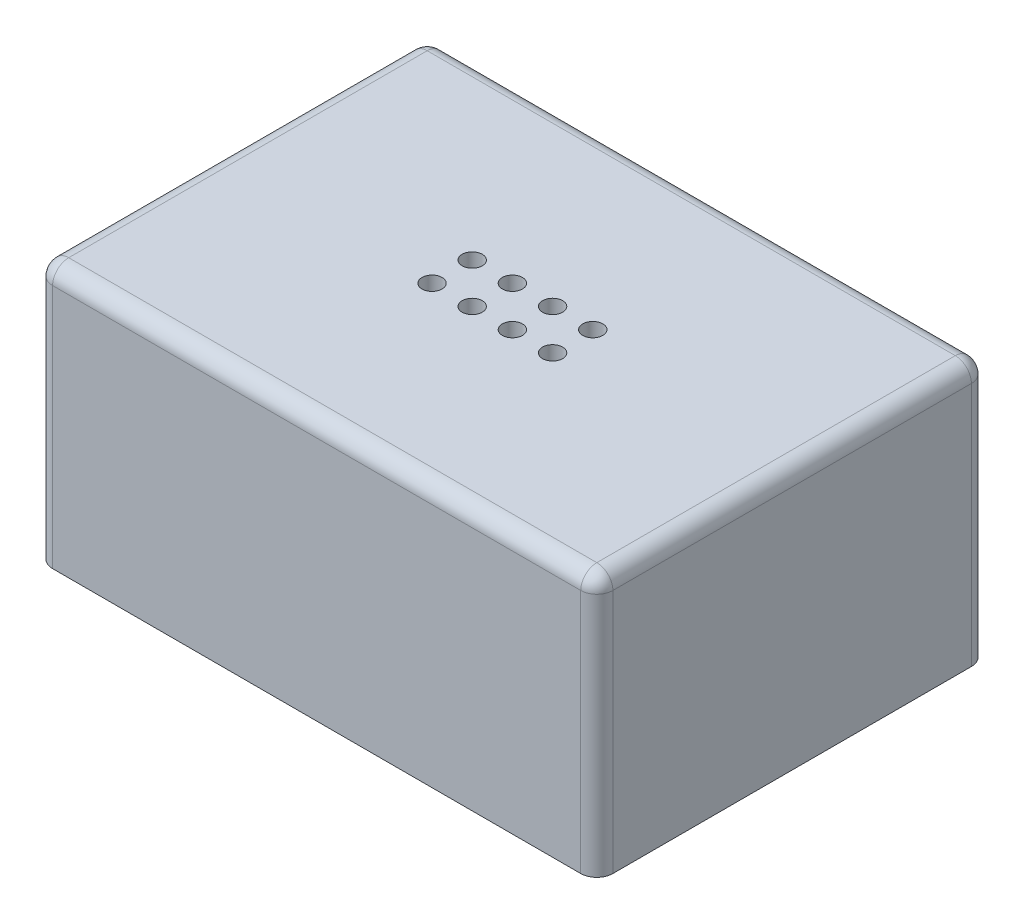
from build123d import *

# Parameters (mm, degrees)
SKETCH3_W           = 88.519
SKETCH3_H           = 61.722
BOSS_EXTRUDE2_DEPTH = 41.275
SKETCH1_W           = 85.344
SKETCH1_H           = 58.547
CUT_EXTRUDE1_DEPTH  = 38.1
FILLET2_R           = 2.54
SKETCH6_R           = 1.5875
CUT_EXTRUDE4_DEPTH  = 42.275
FILLET3_R           = 2.54


with BuildPart() as part:
    # Sketch3 → Boss-Extrude2 (new body)
    with BuildSketch(Plane(origin=(0, 0, 0), x_dir=(1, 0, 0), z_dir=(0, 1, 0))):
        Rectangle(SKETCH3_W, SKETCH3_H)
    extrude(amount=BOSS_EXTRUDE2_DEPTH)

    # Sketch1 → Cut-Extrude1 (cut)
    with BuildSketch(Plane(origin=(0, 0, 0), x_dir=(1, 0, 0), z_dir=(0, 1, 0))):
        Rectangle(SKETCH1_W, SKETCH1_H)
    extrude(amount=CUT_EXTRUDE1_DEPTH, mode=Mode.SUBTRACT)

    # Fillet2
    fillet2_edges = [part.edges().sort_by_distance(p)[0] for p in [
        (-44.2595, 41.275, 0),
        (0, 41.275, 30.861),
        (44.2595, 41.275, 0),
        (0, 41.275, -30.861),
        (44.2595, 20.6375, 30.861),
        (-44.2595, 20.6375, 30.861),
        (-44.2595, 20.6375, -30.861),
        (44.2595, 20.6375, -30.861),
    ]]
    fillet(fillet2_edges, radius=FILLET2_R)

    # Sketch6 → Cut-Extrude4 (cut, through all)
    with BuildSketch(Plane(origin=(0, 41.275, 0), x_dir=(1, 0, 0), z_dir=(0, 1, 0))):
        with Locations(Location((-9.525, -3.1115, 0), (0, 0, 270))):  # turned: the seam where the file's is
            Circle(SKETCH6_R)
        with Locations(Location((-3.175, -3.1115, 0), (0, 0, 270))):  # turned: the seam where the file's is
            Circle(SKETCH6_R)
        with Locations(Location((3.175, -3.1115, 0), (0, 0, 270))):  # turned: the seam where the file's is
            Circle(SKETCH6_R)
        with Locations(Location((9.525, -3.1115, 0), (0, 0, 270))):  # turned: the seam where the file's is
            Circle(SKETCH6_R)
        with Locations(Location((-9.525, 3.2385, 0), (0, 0, 270))):  # turned: the seam where the file's is
            Circle(SKETCH6_R)
        with Locations(Location((-3.175, 3.2385, 0), (0, 0, 270))):  # turned: the seam where the file's is
            Circle(SKETCH6_R)
        with Locations(Location((3.175, 3.2385, 0), (0, 0, 270))):  # turned: the seam where the file's is
            Circle(SKETCH6_R)
        with Locations(Location((9.525, 3.2385, 0), (0, 0, 270))):  # turned: the seam where the file's is
            Circle(SKETCH6_R)
    extrude(amount=-CUT_EXTRUDE4_DEPTH, mode=Mode.SUBTRACT)

    # Fillet3
    fillet3_edges = [part.edges().sort_by_distance(p)[0] for p in [
        (42.672, 38.1, 0),
        (0, 38.1, -29.2735),
        (-42.672, 38.1, 0),
        (0, 38.1, 29.2735),
    ]]
    fillet(fillet3_edges, radius=FILLET3_R)


solid = part.part
